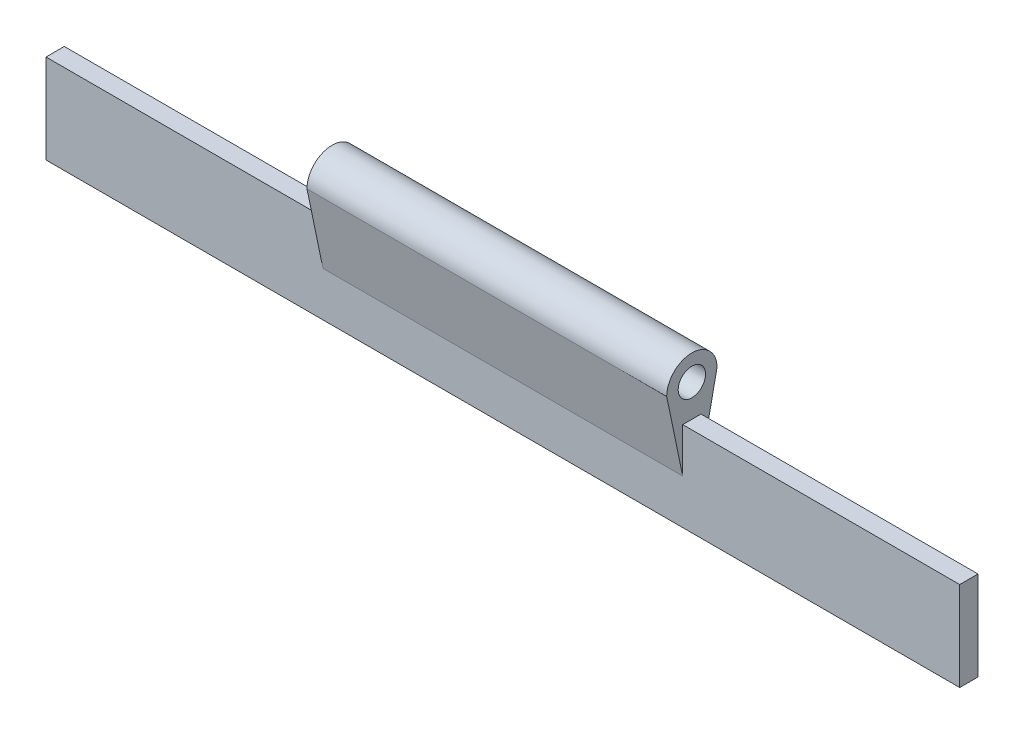
from build123d import *

# Parameters (mm, degrees)
SKETCH1_W           = 127
SKETCH1_H           = 12.4
BOSS_EXTRUDE1_DEPTH = 2.54
SKETCH2_R           = 1.9
BOSS_EXTRUDE3_DEPTH = 25
BOSS_EXTRUDE4_START = -25
SKETCH2_2_R         = 1.9
BOSS_EXTRUDE4_DEPTH = 25


with BuildPart() as part:
    # Sketch1 → Boss-Extrude1 (new body)
    with BuildSketch(Plane.XY):
        with Locations((0, 6.2)):
            Rectangle(SKETCH1_W, SKETCH1_H)
    extrude(amount=BOSS_EXTRUDE1_DEPTH)

    # Sketch2 → Boss-Extrude3 (add)
    with BuildSketch(Plane(origin=(0, 0, 0), x_dir=(0, 0, -1), z_dir=(1, 0, 0))):
        with BuildLine():
            Line((-2.54, 6.2), (-4.77, 16.9))
            ThreePointArc((-4.77, 16.9), (-1.27, 20.4), (2.23, 16.9))
            Line((2.23, 16.9), (0, 6.2))
            Line((0, 6.2), (-2.54, 6.2))
        make_face()
        with Locations((-1.27, 16.9)):
            Circle(SKETCH2_R, mode=Mode.SUBTRACT)
    extrude(amount=BOSS_EXTRUDE3_DEPTH)

    # Sketch2_2 → Boss-Extrude4 (add)
    with BuildSketch(Plane(origin=(0, 0, 0), x_dir=(0, 0, -1), z_dir=(1, 0, 0)).offset(BOSS_EXTRUDE4_START)):
        with BuildLine():
            Line((-2.54, 6.2), (-4.77, 16.9))
            ThreePointArc((-4.77, 16.9), (-1.27, 20.4), (2.23, 16.9))
            Line((2.23, 16.9), (0, 6.2))
            Line((0, 6.2), (-2.54, 6.2))
        make_face()
        with Locations((-1.27, 16.9)):
            Circle(SKETCH2_2_R, mode=Mode.SUBTRACT)
    extrude(amount=BOSS_EXTRUDE4_DEPTH)


solid = part.part
